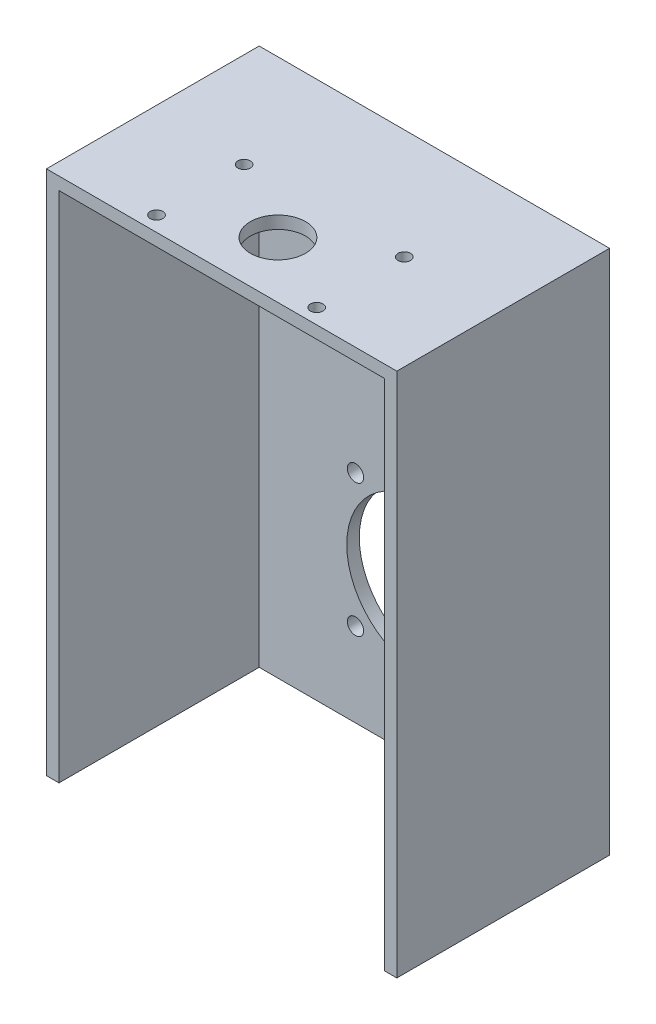
from build123d import *

# Parameters (mm, degrees)
SKETCH_1_R          = 13
EXTRUDE_1_DEPTH     = 20
SKETCH_2_R          = 13
EXTRUDE_2_DEPTH     = 400
SKETCH_4_W          = 140
SKETCH_4_H          = 85
EXTRUDE_3_DEPTH     = 210
SHELL_2_T           = -5
SKETCH_5_W          = 130
SKETCH_5_H          = 5
CUT_EXTRUDE_3_DEPTH = 80
SKETCH_6_R          = 30
SKETCH_6_R_2        = 3.25
CUT_EXTRUDE_4_DEPTH = 10
SKETCH_3_R          = 11
CUT_EXTRUDE_5_DEPTH = 425
SKETCH_7_R          = 13
CUT_EXTRUDE_6_DEPTH = 420
SKETCH_8_R          = 2.5
CUT_EXTRUDE_7_DEPTH = 5


with BuildPart() as part:
    # 草图1 → 凸台-拉伸1 (new body)
    with BuildSketch(Plane(origin=(0, 0, 0), x_dir=(1, 0, 0), z_dir=(0, 1, 0))):
        Circle(SKETCH_1_R)
    extrude(amount=EXTRUDE_1_DEPTH)

    # 草图2 → 凸台-拉伸2 (add)
    with BuildSketch(Plane(origin=(0, 20, 0), x_dir=(1, 0, 0), z_dir=(0, 1, 0))):
        Circle(SKETCH_2_R)
    extrude(amount=EXTRUDE_2_DEPTH)


with BuildPart() as body_2:
    # 草图4 → 凸台-拉伸3 (new body)
    with BuildSketch(Plane.XZ):
        with Locations((0, -20)):
            Rectangle(SKETCH_4_W, SKETCH_4_H)
    extrude(amount=EXTRUDE_3_DEPTH)

    # 抽壳2
    shell_2_openings = [body_2.faces().sort_by_distance(p)[0] for p in [
        (0, -105, 22.5),
    ]]
    offset(amount=SHELL_2_T, openings=shell_2_openings, kind=Kind.INTERSECTION)

    # 草图5 → 切除-拉伸3 (cut)
    with BuildSketch(Plane.XY.offset(22.5)):
        with Locations((0, -207.5)):
            Rectangle(SKETCH_5_W, SKETCH_5_H)
    extrude(amount=-CUT_EXTRUDE_3_DEPTH, mode=Mode.SUBTRACT)

    # 草图6 → 切除-拉伸4 (cut)
    with BuildSketch(Plane(origin=(0, 0, -62.5), x_dir=(-1, 0, 0), z_dir=(0, 0, -1))):
        with Locations((0, -150)):
            Circle(SKETCH_6_R)
        with Locations((26.516504294, -123.483495706)):
            Circle(SKETCH_6_R_2)
        with Locations((26.516504294, -176.516504294)):
            Circle(SKETCH_6_R_2)
        with Locations((-26.516504294, -176.516504294)):
            Circle(SKETCH_6_R_2)
        with Locations((-26.516504294, -123.483495706)):
            Circle(SKETCH_6_R_2)
    extrude(amount=-CUT_EXTRUDE_4_DEPTH, mode=Mode.SUBTRACT)


with BuildPart() as cut_extrude_5_tool:
    # 草图3 → 切除-拉伸5 (new body)
    with BuildSketch(Plane(origin=(0, 420, 0), x_dir=(1, 0, 0), z_dir=(0, 1, 0))):
        Circle(SKETCH_3_R)
    extrude(amount=-CUT_EXTRUDE_5_DEPTH)


with BuildPart() as part_1:
    add(part.part)

    # 切除-拉伸5: cut by cut_extrude_5_tool
    add(cut_extrude_5_tool.part, mode=Mode.SUBTRACT)

    # 草图7 → 切除-拉伸6 (cut)
    with BuildSketch(Plane(origin=(0, 420, 0), x_dir=(1, 0, 0), z_dir=(0, 1, 0))):
        Circle(SKETCH_7_R)
    extrude(amount=-CUT_EXTRUDE_6_DEPTH, mode=Mode.SUBTRACT)


with BuildPart() as body_2_1:
    add(body_2.part)

    # 切除-拉伸5: cut by cut_extrude_5_tool
    add(cut_extrude_5_tool.part, mode=Mode.SUBTRACT)

    # 草图8 → 切除-拉伸7 (cut)
    with BuildSketch(Plane(origin=(0, 0, 0), x_dir=(1, 0, 0), z_dir=(0, 1, 0))):
        with Locations((-32.020865922, -16.5)):
            Circle(SKETCH_8_R)
        with Locations((-32.020865922, 18.5)):
            Circle(SKETCH_8_R)
        with Locations((31.979134078, -16.5)):
            Circle(SKETCH_8_R)
        with Locations((31.979134078, 18.5)):
            Circle(SKETCH_8_R)
    extrude(amount=-CUT_EXTRUDE_7_DEPTH, mode=Mode.SUBTRACT)


solid = body_2_1.part
